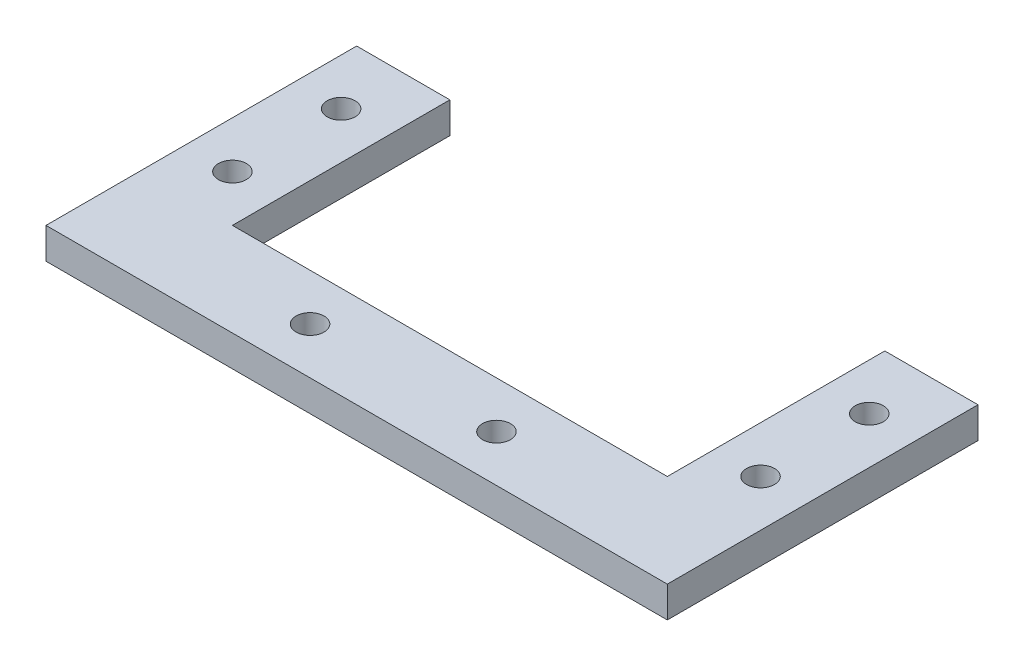
from build123d import *

# Parameters (mm, degrees)
SKETCH1_R           = 4.5
BOSS_EXTRUDE1_DEPTH = 10


with BuildPart() as part:
    # Sketch1 → Boss-Extrude1 (new body)
    with BuildSketch(Plane(origin=(0, 0, 0), x_dir=(1, 0, 0), z_dir=(0, 1, 0))):
        Polygon((0, 0), (-200, 0), (-200, 100), (-170, 100), (-170, 30), (-30, 30), (-30, 100), (0, 100), align=None)
        with Locations((-15, 80)):
            Circle(SKETCH1_R, mode=Mode.SUBTRACT)
        with Locations((-15, 45)):
            Circle(SKETCH1_R, mode=Mode.SUBTRACT)
        with Locations((-130, 15)):
            Circle(SKETCH1_R, mode=Mode.SUBTRACT)
        with Locations((-70, 15)):
            Circle(SKETCH1_R, mode=Mode.SUBTRACT)
        with Locations((-185, 80)):
            Circle(SKETCH1_R, mode=Mode.SUBTRACT)
        with Locations((-185, 45)):
            Circle(SKETCH1_R, mode=Mode.SUBTRACT)
    extrude(amount=BOSS_EXTRUDE1_DEPTH)


solid = part.part
